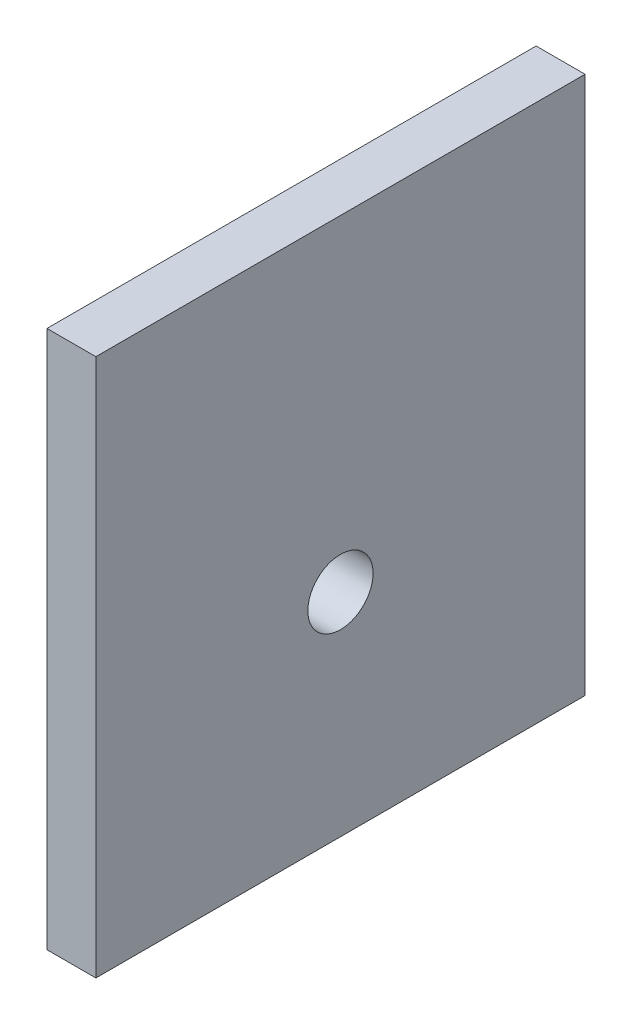
from build123d import *

# Parameters (mm, degrees)
SKETCH_1_W          = 30
SKETCH_1_H          = 40
EXTRUDE_1_DEPTH     = 3
SKETCH_2_R          = 2
CUT_EXTRUDE_1_DEPTH = 4
SKETCH_3_W          = 30
SKETCH_3_H          = 7
CUT_EXTRUDE_2_DEPTH = 4


with BuildPart() as part:
    # 草图1 → 凸台-拉伸1 (new body)
    with BuildSketch(Plane(origin=(0, 0, 0), x_dir=(0, 0, -1), z_dir=(1, 0, 0))):
        Rectangle(SKETCH_1_W, SKETCH_1_H)
    extrude(amount=EXTRUDE_1_DEPTH)

    # 草图2 → 切除-拉伸1 (cut, through all)
    with BuildSketch(Plane(origin=(3, 0, 0), x_dir=(0, 0, -1), z_dir=(1, 0, 0))):
        Circle(SKETCH_2_R)
    extrude(amount=-CUT_EXTRUDE_1_DEPTH, mode=Mode.SUBTRACT)

    # 草图3 → 切除-拉伸2 (cut, through all)
    with BuildSketch(Plane.ZY):
        with Locations((0, -16.5)):
            Rectangle(SKETCH_3_W, SKETCH_3_H)
    extrude(amount=-CUT_EXTRUDE_2_DEPTH, mode=Mode.SUBTRACT)


solid = part.part
